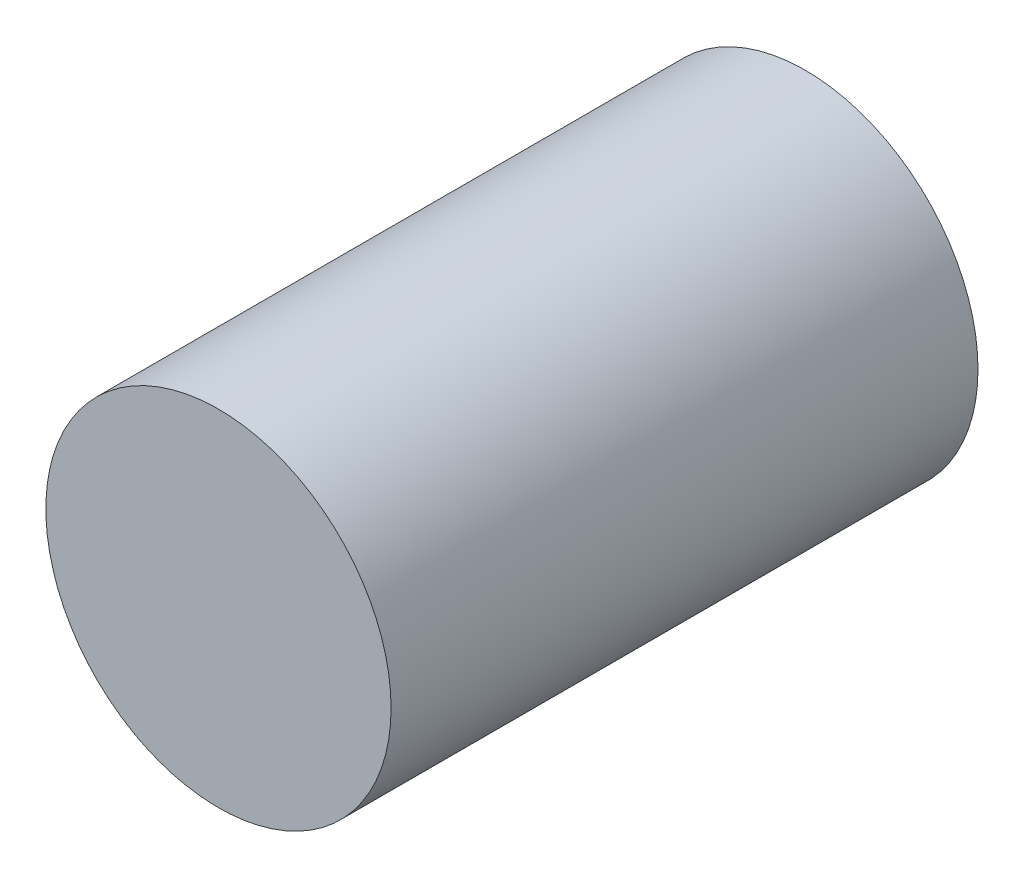
from build123d import *

# Parameters (mm, degrees)
ESQUISSE1_R        = 25
BOSS_EXTRU_1_DEPTH = 85


with BuildPart() as part:
    # Esquisse1 → Boss.-Extru.1 (new body)
    with BuildSketch(Plane.XY):
        Circle(ESQUISSE1_R)
    extrude(amount=BOSS_EXTRU_1_DEPTH)


solid = part.part
